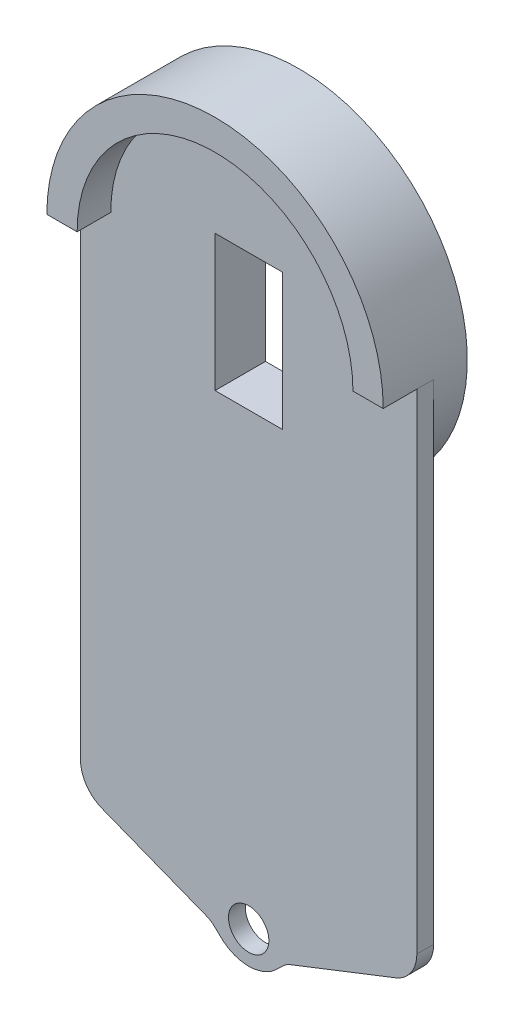
from build123d import *

# Parameters (mm, degrees)
CROQUIS1_R              = 6
SALIENTE_EXTRUIR1_DEPTH = 5
REDONDEO1_R             = 10
REDONDEO3_R             = 10
CROQUIS2_R              = 50
CROQUIS2_R_2            = 41
SALIENTE_EXTRUIR3_DEPTH = 10
CROQUIS3_W              = 20
CROQUIS3_H              = 40.5
CORTAR_EXTRUIR1_DEPTH   = 10
CORTAR_EXTRUIR2_DEPTH   = 10
CROQUIS5_R              = 50
SALIENTE_EXTRUIR4_DEPTH = 10


with BuildPart() as part:
    # Croquis1 → Saliente-Extruir1 (new body)
    with BuildSketch(Plane.XY):
        with BuildLine():
            ThreePointArc((50, 164), (0, 214), (-50, 164))
            Line((-50, 164), (-50, 11.739233328))
            Line((-50, 11.739233328), (-20, 0))
            Line((-20, 0), (-13.787308542, -2.431074487))
            add(Edge.make_bspline(
                [(-8.854817181, -5.677302066), (-9.51760475, -5.090344722), (-10.900654261, -3.469047842), (-12.711160318, -2.852179657), (-13.787308542, -2.431074487)],
                knots=[0.517708821, 0.517708821, 0.517708821, 0.517708821, 0.741171884, 1, 1, 1, 1], degree=3))
            ThreePointArc((-8.854817181, -5.677302066), (0, -9.578400122), (8.854817181, -5.677302066))
            add(Edge.make_bspline(
                [(8.854817181, -5.677302066), (9.51760475, -5.090344722), (10.900654261, -3.469047842), (12.711160318, -2.852179657), (13.787308542, -2.431074487)],
                knots=[0.517708821, 0.517708821, 0.517708821, 0.517708821, 0.741171884, 1, 1, 1, 1], degree=3))
            Line((13.787308542, -2.431074487), (20, 0))
            Line((20, 0), (50, 11.739233328))
            Line((50, 11.739233328), (50, 164))
        make_face()
        Circle(CROQUIS1_R, mode=Mode.SUBTRACT)
    extrude(amount=SALIENTE_EXTRUIR1_DEPTH)

    # Redondeo1
    redondeo1_edges = [part.edges().sort_by_distance(p)[0] for p in [
        (50, 11.739233328, 2.5),
    ]]
    fillet(redondeo1_edges, radius=REDONDEO1_R)

    # Redondeo3
    redondeo3_edges = [part.edges().sort_by_distance(p)[0] for p in [
        (-50, 11.739233328, 2.5),
    ]]
    fillet(redondeo3_edges, radius=REDONDEO3_R)

    # Croquis2 → Saliente-Extruir3 (add)
    with BuildSketch(Plane.XY.offset(5)):
        with Locations((0, 164)):
            Circle(CROQUIS2_R)
        with Locations((0, 164)):
            Circle(CROQUIS2_R_2, mode=Mode.SUBTRACT)
    extrude(amount=SALIENTE_EXTRUIR3_DEPTH)

    # Croquis3 → Cortar-Extruir1 (cut)
    with BuildSketch(Plane(origin=(0, 0, 0), x_dir=(-1, 0, 0), z_dir=(0, 0, -1))):
        with Locations((0, 153.891101056)):
            Rectangle(CROQUIS3_W, CROQUIS3_H)
    extrude(amount=-CORTAR_EXTRUIR1_DEPTH, mode=Mode.SUBTRACT)

    # Croquis4 → Cortar-Extruir2 (cut)
    with BuildSketch(Plane.XY.offset(15)):
        with BuildLine():
            Line((-41, 164), (-50, 164))
            ThreePointArc((-50, 164), (0, 114), (50, 164))
            Line((50, 164), (41, 164))
            ThreePointArc((41, 164), (0, 123), (-41, 164))
        make_face()
    extrude(amount=-CORTAR_EXTRUIR2_DEPTH, mode=Mode.SUBTRACT)

    # Croquis5 → Saliente-Extruir4 (add)
    with BuildSketch(Plane(origin=(0, 0, 0), x_dir=(-1, 0, 0), z_dir=(0, 0, -1))):
        with Locations((0, 164)):
            Circle(CROQUIS5_R)
        Polygon((-10, 174.141101056), (-8, 174.141101056), (-8, 194.141101056), (8, 194.141101056), (8, 174.141101056), (10, 174.141101056), (10, 133.641101056), (-10, 133.641101056), align=None, mode=Mode.SUBTRACT)
    extrude(amount=SALIENTE_EXTRUIR4_DEPTH)


solid = part.part
